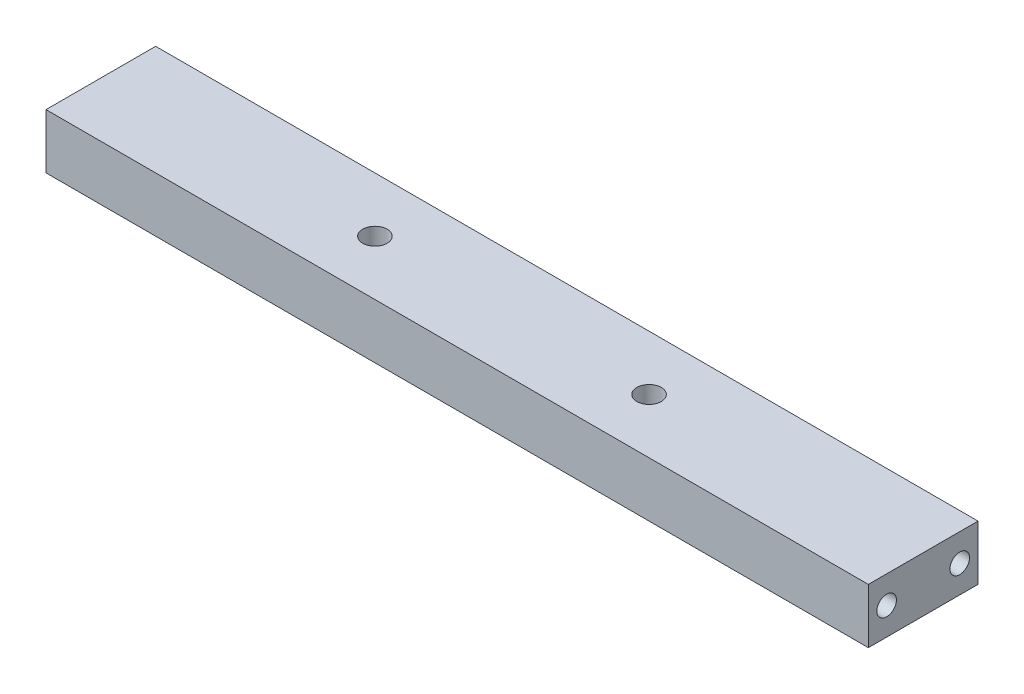
from build123d import *

# Parameters (mm, degrees)
SKETCH1_W                       = 38.1
SKETCH1_H                       = 19.05
EXTRUDE1_DEPTH                  = 142.875
M8X1_25_TAPPED_HOLE1_AT_2_COUNT = 2
M8X1_25_TAPPED_HOLE1_AT_2_PITCH = 25.4
M10X1_5_TAPPED_HOLE1_D          = 8.5
M5X0_8_TAPPED_HOLE2_D           = 4.2
M5X0_8_TAPPED_HOLE2_DEPTH       = 12.3952
M5X0_8_TAPPED_HOLE2_TIP         = 1.2618073
M5X0_8_TAPPED_HOLE3_D           = 4.2
M5X0_8_TAPPED_HOLE3_DEPTH       = 12.3952
M5X0_8_TAPPED_HOLE3_TIP         = 1.2618073


with BuildPart() as part:
    # Sketch1 → Extrude1 (new, symmetric)
    with BuildSketch(Plane(origin=(0, 0, 0), x_dir=(0, 0, -1), z_dir=(1, 0, 0))):
        Rectangle(SKETCH1_W, SKETCH1_H)
    extrude(amount=EXTRUDE1_DEPTH, both=True)

    # Sketch2 → M8x1.25 Tapped Hole1 (revolve, cut)
    with BuildSketch(Plane(origin=(142.875, 0, 12.7), x_dir=(0, 0, -1), z_dir=(0, 1, 0))):
        Polygon((0, 0), (0, 21.804126105), (3.4, 19.7612), (3.4, 0), align=None)
    m8x1_25_tapped_hole1 = revolve(axis=Axis((149.225, 0, 12.7), (-1, 0, 0)), mode=Mode.SUBTRACT)

    # M8x1.25 Tapped Hole1 at 2: M8x1.25 Tapped Hole1 ×2
    with Locations(*[(0, 0, -i * M8X1_25_TAPPED_HOLE1_AT_2_PITCH) for i in range(1, M8X1_25_TAPPED_HOLE1_AT_2_COUNT)]):
        add(m8x1_25_tapped_hole1, mode=Mode.SUBTRACT)

    # Mirror1: M8x1.25 Tapped Hole1 across plane
    add(m8x1_25_tapped_hole1.mirror(Plane(origin=(0, 0, 0), x_dir=(0, 0, 1), z_dir=(1, 0, 0))), mode=Mode.SUBTRACT)

    # Mirror1 copy 1 sketch → Mirror1 copy 1 (revolve, cut)
    with BuildSketch(Plane(origin=(-142.875, 0, -12.7), x_dir=(0, 0, -1), z_dir=(0, 1, 0))):
        Polygon((0, 0), (0, -21.804126105), (3.4, -19.7612), (3.4, 0), align=None)
    revolve(axis=Axis((-149.225, 0, -12.7), (-1, 0, 0)), mode=Mode.SUBTRACT)

    # M10x1.5 Tapped Hole1 (through all)
    with Locations(Plane(origin=(0, 9.525, 0), x_dir=(-1, 0, 0), z_dir=(0, 1, 0))):
        with Locations((47.625, 0), (-47.625, 0)):
            Hole(M10X1_5_TAPPED_HOLE1_D / 2)

    # M5x0.8 Tapped Hole2
    with Locations(Plane(origin=(-9.051259955, 7.173736758, -19.05), x_dir=(1, 0, 0), z_dir=(0, 0, -1))):
        with Locations((72.551259955, 7.173736758), (-54.448740045, 7.173736758)):
            Hole(M5X0_8_TAPPED_HOLE2_D / 2, depth=M5X0_8_TAPPED_HOLE2_DEPTH)
            with Locations((0, 0, -(M5X0_8_TAPPED_HOLE2_DEPTH + M5X0_8_TAPPED_HOLE2_TIP / 2))):  # 118° drill point
                Cone(0, M5X0_8_TAPPED_HOLE2_D / 2, M5X0_8_TAPPED_HOLE2_TIP, mode=Mode.SUBTRACT)

    # M5x0.8 Tapped Hole3
    with Locations(Plane(origin=(0, -9.525, 0), x_dir=(-1, 0, 0), z_dir=(0, -1, 0))):
        with Locations((-19.05, 12.7), (19.05, 12.7), (19.05, -12.7), (-19.05, -12.7)):
            Hole(M5X0_8_TAPPED_HOLE3_D / 2, depth=M5X0_8_TAPPED_HOLE3_DEPTH)
            with Locations((0, 0, -(M5X0_8_TAPPED_HOLE3_DEPTH + M5X0_8_TAPPED_HOLE3_TIP / 2))):  # 118° drill point
                Cone(0, M5X0_8_TAPPED_HOLE3_D / 2, M5X0_8_TAPPED_HOLE3_TIP, mode=Mode.SUBTRACT)


solid = part.part
